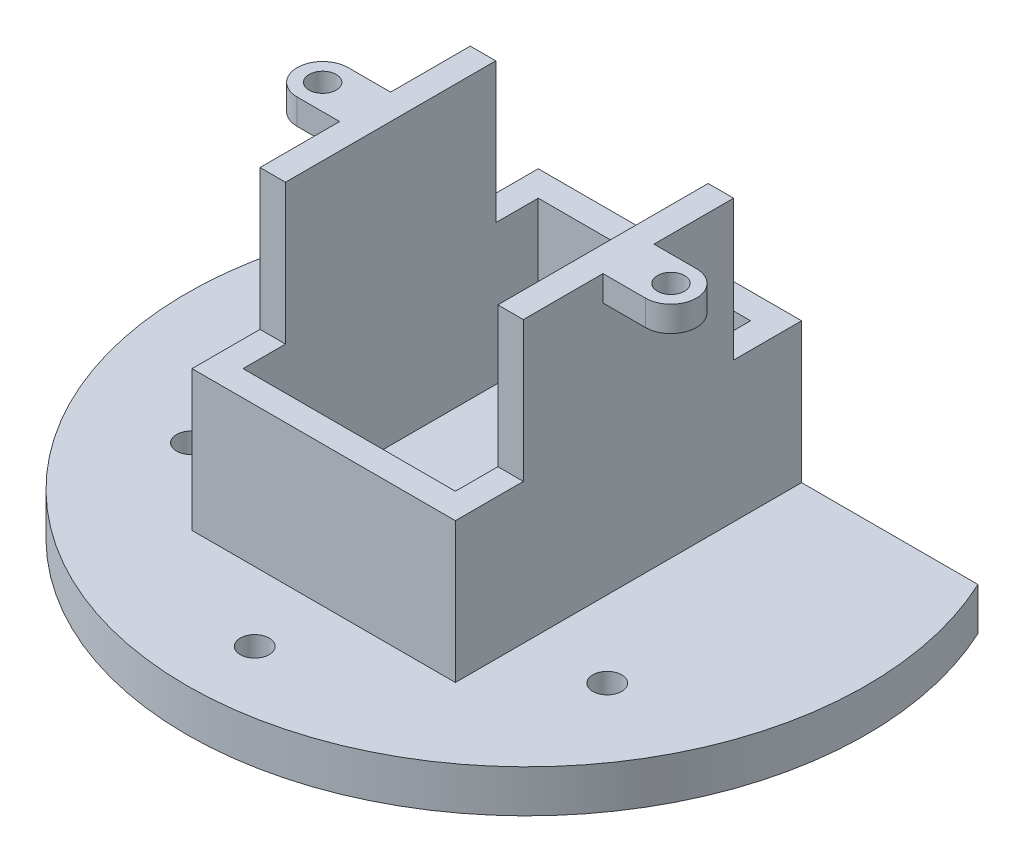
from build123d import *

# Parameters (mm, degrees)
SKETCH_1_W          = 31
SKETCH_1_H          = 38
EXTRUDE_1_DEPTH     = 40.75
SKETCH_2_W          = 8
SKETCH_2_H          = 16.5
CUT_EXTRUDE_1_DEPTH = 40.75
SKETCH_3_W          = 25
SKETCH_3_H          = 34.75
CUT_EXTRUDE_2_DEPTH = 34.5
SKETCH_4_R          = 12.5
CUT_EXTRUDE_3_DEPTH = 34.5
SKETCH_5_R          = 1.6
EXTRUDE_2_DEPTH     = 3
EXTRUDE_5_DEPTH     = 5
SKETCH_9_R          = 1.7
CUT_EXTRUDE_4_DEPTH = 10
SKETCH_11_R         = 1.7
CUT_EXTRUDE_5_DEPTH = 10
SKETCH_12_W         = 31
SKETCH_12_H         = 16.5
CUT_EXTRUDE_6_DEPTH = 8


with BuildPart() as part:
    # 草图1 → 凸台-拉伸1 (new body)
    with BuildSketch(Plane.XY):
        with Locations((15.5, 19)):
            Rectangle(SKETCH_1_W, SKETCH_1_H)
    extrude(amount=-EXTRUDE_1_DEPTH)

    # 草图2 → 切除-拉伸1 (cut)
    with BuildSketch(Plane(origin=(31, 0, 0), x_dir=(0, 0, -1), z_dir=(1, 0, 0))):
        with Locations((36.75, 29.75)):
            Rectangle(SKETCH_2_W, SKETCH_2_H)
    extrude(amount=-CUT_EXTRUDE_1_DEPTH, mode=Mode.SUBTRACT)

    # 草图3 → 切除-拉伸2 (cut)
    with BuildSketch(Plane(origin=(0, 38, 0), x_dir=(1, 0, 0), z_dir=(0, 1, 0))):
        with Locations((15.5, 20.375)):
            Rectangle(SKETCH_3_W, SKETCH_3_H)
    extrude(amount=-CUT_EXTRUDE_2_DEPTH, mode=Mode.SUBTRACT)

    # 草图4 → 切除-拉伸3 (cut)
    with BuildSketch(Plane.XY):
        with Locations((15.5, 38)):
            Circle(SKETCH_4_R)
    extrude(amount=-CUT_EXTRUDE_3_DEPTH, mode=Mode.SUBTRACT)

    # 草图5 → 凸台-拉伸2 (add)
    with BuildSketch(Plane(origin=(0, 38, 0), x_dir=(1, 0, 0), z_dir=(0, 1, 0))):
        with BuildLine():
            Line((36, 23.375), (31, 23.375))
            Line((31, 23.375), (31, 17.375))
            Line((31, 17.375), (36, 17.375))
            ThreePointArc((36, 17.375), (39, 20.375), (36, 23.375))
        make_face()
        with Locations((36, 20.375)):
            Circle(SKETCH_5_R, mode=Mode.SUBTRACT)
        with BuildLine():
            Line((0, 23.375), (0, 17.375))
            Line((0, 17.375), (-5, 17.375))
            ThreePointArc((-5, 17.375), (-8, 20.375), (-5, 23.375))
            Line((-5, 23.375), (0, 23.375))
        make_face()
        with Locations((-5, 20.375)):
            Circle(SKETCH_5_R, mode=Mode.SUBTRACT)
    extrude(amount=-EXTRUDE_2_DEPTH)

    # 草图8 → 凸台-拉伸5 (add)
    with BuildSketch(Plane.XZ):
        with BuildLine():
            Line((-20.766160191, -40.75), (51.766160191, -40.75))
            ThreePointArc((51.766160191, -40.75), (15.5, 16.125), (-20.766160191, -40.75))
        make_face()
    extrude(amount=-EXTRUDE_5_DEPTH)

    # 草图9 → 切除-拉伸4 (cut)
    with BuildSketch(Plane(origin=(0, 5, 0), x_dir=(1, 0, 0), z_dir=(0, 1, 0))):
        with Locations((40, 8.875)):
            Circle(SKETCH_9_R)
        with Locations((-9, 8.875)):
            Circle(SKETCH_9_R)
    extrude(amount=-CUT_EXTRUDE_4_DEPTH, mode=Mode.SUBTRACT)

    # 草图11 → 切除-拉伸5 (cut)
    with BuildSketch(Plane(origin=(0, 5, 0), x_dir=(1, 0, 0), z_dir=(0, 1, 0))):
        with Locations((15.5, -8.125)):
            Circle(SKETCH_11_R)
    extrude(amount=-CUT_EXTRUDE_5_DEPTH, mode=Mode.SUBTRACT)

    # 草图12 → 切除-拉伸6 (cut)
    with BuildSketch(Plane.XY):
        with Locations((15.5, 29.75)):
            Rectangle(SKETCH_12_W, SKETCH_12_H)
    extrude(amount=-CUT_EXTRUDE_6_DEPTH, mode=Mode.SUBTRACT)


solid = part.part
